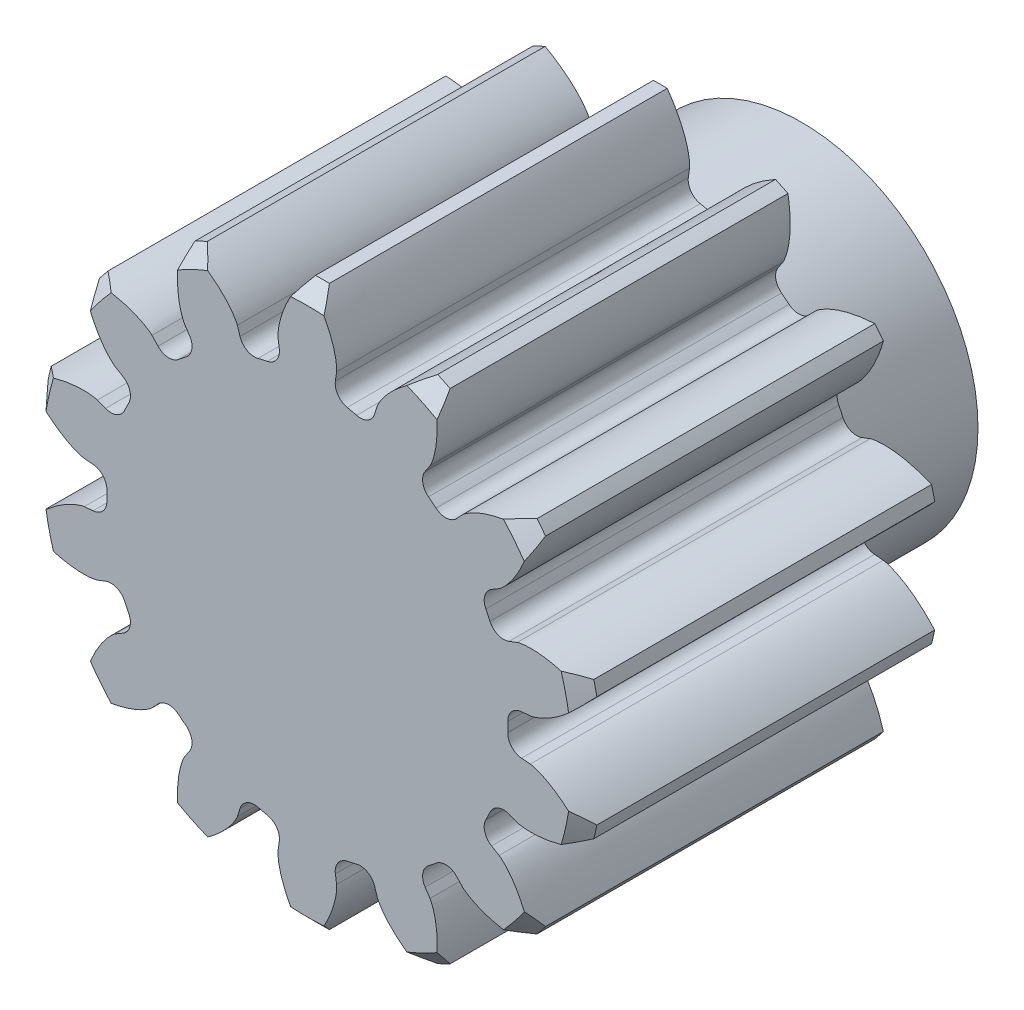
from build123d import *
from build123d.topology import SkipClean

# Parameters (mm, degrees)
SKETCH1_R                = 8
BOSS_EXTRUDE1_DEPTH      = 10
CUT_EXTRUDE1_DEPTH       = 16.099668871
FILLET1_R                = 0.355654565
FILLET2_R                = 0.355654565
CIRPATTERN1_COUNT        = 14
FILLET1_OF_CIRPATTERN1_R = 0.355654565
FILLET2_OF_CIRPATTERN1_R = 0.355654565
SKETCH4_R                = 2
BORE_DEPTH               = 16.019584955
SKETCH5_R                = 16
TOLERANCE_DEPTH          = 16.019584955
SKETCH7_R                = 5
SKETCH7_R_2              = 2
BOSS_EXTRUDE2_DEPTH      = 4
SKETCH8_R                = 2
BOSS_EXTRUDE3_DEPTH      = 4.2


with BuildPart() as part:
    # Sketch1 → Boss-Extrude1 (new body)
    with BuildSketch(Plane.XY):
        Circle(SKETCH1_R)
    extrude(amount=BOSS_EXTRUDE1_DEPTH)

    # Sketch2 → Cut-Extrude1 (cut, through all)
    with BuildSketch(Plane.XY.offset(10)):
        with BuildLine():
            Line((5.730573503, 0.472257693), (6.322720648, 0.521056656))
            add(Edge.make_bspline(
                [(6.322720648, 0.521056656), (6.325475459, 0.521328821), (6.333187667, 0.52223076), (6.347707195, 0.52448275), (6.371287999, 0.52893086), (6.414835682, 0.538848261), (6.466578901, 0.553467251), (6.52440654, 0.572634304), (6.585867562, 0.595867869), (6.637954923, 0.617357051), (6.68945384, 0.640294185), (6.740319148, 0.664489833), (6.801385563, 0.695375748), (6.873827242, 0.734595986), (6.957273971, 0.783580487), (7.050401835, 0.842814847), (7.143579001, 0.907050749), (7.233800283, 0.973416262), (7.323161939, 1.044027003), (7.408343747, 1.114864038), (7.494851143, 1.191992044), (7.573708707, 1.265000125), (7.65975709, 1.350629543), (7.728537068, 1.420862176), (7.797590498, 1.496542262), (7.83090097, 1.533834574), (7.847797593, 1.553084977)],
                knots=[0, 0, 0, 0, 0, 0.005376749, 0.015083688, 0.02853182, 0.046610139, 0.092110525, 0.119476176, 0.146842496, 0.174208854, 0.201574956, 0.228941013, 0.256307345, 0.307035032, 0.361767352, 0.416499661, 0.471231937, 0.525964282, 0.580696615, 0.635428982, 0.690161387, 0.744893688, 0.799626082, 0.854358408, 0.909090915, 0.909090915, 0.909090915, 0.909090915, 0.909090915], degree=4))
            ThreePointArc((7.847797593, 1.553084977), (8, 0), (7.847797593, -1.553084977))
            add(Edge.make_bspline(
                [(6.322720648, -0.521056656), (6.325475459, -0.521328821), (6.333187667, -0.52223076), (6.347707195, -0.52448275), (6.371287999, -0.52893086), (6.414835682, -0.538848261), (6.466578901, -0.553467251), (6.52440654, -0.572634304), (6.585867562, -0.595867869), (6.637954923, -0.617357051), (6.68945384, -0.640294185), (6.740319148, -0.664489833), (6.801385563, -0.695375748), (6.873827242, -0.734595986), (6.957273971, -0.783580487), (7.050401835, -0.842814847), (7.143579001, -0.907050749), (7.233800283, -0.973416262), (7.323161939, -1.044027003), (7.408343747, -1.114864038), (7.494851143, -1.191992044), (7.573708707, -1.265000125), (7.65975709, -1.350629543), (7.728537068, -1.420862176), (7.797590498, -1.496542262), (7.83090097, -1.533834574), (7.847797593, -1.553084977)],
                knots=[0, 0, 0, 0, 0, 0.005376749, 0.015083688, 0.02853182, 0.046610139, 0.092110525, 0.119476176, 0.146842496, 0.174208854, 0.201574956, 0.228941013, 0.256307345, 0.307035032, 0.361767352, 0.416499661, 0.471231937, 0.525964282, 0.580696615, 0.635428982, 0.690161387, 0.744893688, 0.799626082, 0.854358408, 0.909090915, 0.909090915, 0.909090915, 0.909090915, 0.909090915], degree=4))
            Line((6.322720648, -0.521056656), (5.730573503, -0.472257693))
            ThreePointArc((5.730573503, -0.472257693), (5.75, 0), (5.730573503, 0.472257693))
        make_face()
    cut_extrude1 = extrude(amount=-CUT_EXTRUDE1_DEPTH, mode=Mode.SUBTRACT)

    # Fillet1
    fillet1_edges = [part.edges().sort_by_distance(p)[0] for p in [
        (5.730573503, 0.472257693, 5),
    ]]
    fillet(fillet1_edges, radius=FILLET1_R)

    # Fillet2
    fillet2_edges = [part.edges().sort_by_distance(p)[0] for p in [
        (5.730573503, -0.472257693, 5),
    ]]
    fillet(fillet2_edges, radius=FILLET2_R)

    # CirPattern1: Cut-Extrude1 ×14 about axis
    cirpattern1_axis = Axis((0, 0, 10), (0, 0, -1))
    for i in range(1, CIRPATTERN1_COUNT):
        add(cut_extrude1.rotate(cirpattern1_axis, i * 360 / CIRPATTERN1_COUNT), mode=Mode.SUBTRACT)

    # Fillet1 of CirPattern1
    fillet1_of_cirpattern1_edges = [part.edges().sort_by_distance(p)[0] for p in [
        (5.367973255, -2.06091318, 5),
        (3.94218007, -4.185894922, 5),
        (1.735589774, -5.481808838, 5),
        (-0.814755362, -5.691983284, 5),
        (-3.203728206, -4.774790632, 5),
        (-4.958163388, -2.911892137, 5),
        (-5.730573503, -0.472257693, 5),
        (-5.367973255, 2.06091318, 5),
        (-3.94218007, 4.185894922, 5),
        (-1.735589774, 5.481808838, 5),
        (0.814755362, 5.691983284, 5),
        (3.203728206, 4.774790632, 5),
        (4.958163388, 2.911892137, 5),
    ]]
    fillet(fillet1_of_cirpattern1_edges, radius=FILLET1_OF_CIRPATTERN1_R)

    # Fillet2 of CirPattern1
    fillet2_of_cirpattern1_edges = [part.edges().sort_by_distance(p)[0] for p in [
        (4.958163388, -2.911892137, 5),
        (3.203728206, -4.774790632, 5),
        (0.814755362, -5.691983284, 5),
        (-1.735589774, -5.481808838, 5),
        (-3.94218007, -4.185894922, 5),
        (-5.367973255, -2.06091318, 5),
        (-5.730573503, 0.472257693, 5),
        (-4.958163388, 2.911892137, 5),
        (-3.203728206, 4.774790632, 5),
        (-0.814755362, 5.691983284, 5),
        (1.735589774, 5.481808838, 5),
        (3.94218007, 4.185894922, 5),
        (5.367973255, 2.06091318, 5),
    ]]
    fillet(fillet2_of_cirpattern1_edges, radius=FILLET2_OF_CIRPATTERN1_R)

    # Sketch4 → Bore (cut, through all)
    with BuildSketch(Plane.XY.offset(10)):
        Circle(SKETCH4_R)
    extrude(amount=-BORE_DEPTH, mode=Mode.SUBTRACT)

    # Sketch5 → TOLERANCE (cut, through all)
    with BuildSketch(Plane.XY.offset(10)):
        Circle(SKETCH5_R)
        with BuildLine():
            Line((6.316346609, -0.590768668), (6.068945037, -0.570380256))
            ThreePointArc((6.068945037, -0.570380256), (5.787375971, -0.430753494), (5.67837222, -0.135973993))
            ThreePointArc((5.67837222, -0.135973993), (5.68, 0), (5.67837222, 0.135973993))
            ThreePointArc((5.67837222, 0.135973993), (5.787375971, 0.430753494), (6.068945037, 0.570380256))
            Line((6.068945037, 0.570380256), (6.316346609, 0.590768668))
            add(Edge.make_bspline(
                [(6.316346609, 0.590768668), (6.354130738, 0.59464145), (6.390065274, 0.604717133), (6.461766907, 0.625430036), (6.497132103, 0.637415095), (6.602189372, 0.676852433), (6.670525006, 0.707679936), (6.869027417, 0.808304435), (6.994197707, 0.886761429), (7.354770586, 1.145846707), (7.573794334, 1.35105484), (7.772333196, 1.573447389)],
                knots=[0, 0, 0, 0, 0.0625, 0.0625, 0.125, 0.125, 0.25, 0.25, 0.5, 0.5, 1, 1, 1, 1], degree=3))
            ThreePointArc((7.772333196, 1.573447389), (7.731178344, 1.764591006), (7.685323477, 1.954661877))
            add(Edge.make_bspline(
                [(7.685323477, 1.954661877), (7.41025652, 2.068762215), (7.125421755, 2.158361645), (6.686362495, 2.235743079), (6.537881791, 2.252249383), (6.315009659, 2.2566167), (6.203811241, 2.253714765), (6.093111129, 2.240149255), (6.019470965, 2.22768354), (5.9824995, 2.221063392), (5.947156572, 2.208295906)],
                knots=[0, 0, 0, 0, 0.5, 0.5, 0.75, 0.75, 0.875, 0.9375, 0.9375, 1, 1, 1, 1], degree=3))
            Line((5.947156572, 2.208295906), (5.715409258, 2.119321712))
            ThreePointArc((5.715409258, 2.119321712), (5.401142514, 2.122952839), (5.175033496, 2.341245036))
            ThreePointArc((5.175033496, 2.341245036), (5.11750317, 2.464459638), (5.057039686, 2.586261706))
            ThreePointArc((5.057039686, 2.586261706), (5.027348641, 2.899143814), (5.220451822, 3.147111419))
            Line((5.220451822, 3.147111419), (5.434506735, 3.272824263))
            add(Edge.make_bspline(
                [(5.434506735, 3.272824263), (5.466868721, 3.292707438), (5.494872946, 3.317376725), (5.550486892, 3.367148579), (5.57714971, 3.393291127), (5.654691819, 3.474405581), (5.702884547, 3.531829922), (5.838069705, 3.708616432), (5.916803026, 3.833613094), (6.129255075, 4.223487573), (6.237552181, 4.503404555), (6.319937005, 4.789916101)],
                knots=[0, 0, 0, 0, 0.0625, 0.0625, 0.125, 0.125, 0.25, 0.25, 0.5, 0.5, 1, 1, 1, 1], degree=3))
            ThreePointArc((6.319937005, 4.789916101), (6.199923656, 4.944274129), (6.076141189, 5.095626385))
            add(Edge.make_bspline(
                [(6.076141189, 5.095626385), (5.778808143, 5.079080157), (5.483305151, 5.036221282), (5.054151881, 4.915438871), (4.913213572, 4.865887174), (4.710517812, 4.773121397), (4.611590602, 4.722259658), (4.517739101, 4.662006578), (4.456800277, 4.618824087), (4.426362512, 4.596818222), (4.400059239, 4.569980393)],
                knots=[0, 0, 0, 0, 0.5, 0.5, 0.75, 0.75, 0.875, 0.9375, 0.9375, 1, 1, 1, 1], degree=3))
            Line((4.400059239, 4.569980393), (4.22986658, 4.389266023))
            ThreePointArc((4.22986658, 4.389266023), (3.94514654, 4.256182325), (3.646715919, 4.354751773))
            ThreePointArc((3.646715919, 4.354751773), (3.541422075, 4.44080282), (3.434098422, 4.524308569))
            ThreePointArc((3.434098422, 4.524308569), (3.271593255, 4.793323146), (3.337984098, 5.100518568))
            Line((3.337984098, 5.100518568), (3.476296152, 5.306656873))
            add(Edge.make_bspline(
                [(3.476296152, 5.306656873), (3.496826308, 5.338612335), (3.51135364, 5.372989172), (3.539864876, 5.44196205), (3.552544419, 5.477084235), (3.587213202, 5.583810093), (3.605717861, 5.656457678), (3.650810688, 5.874391461), (3.66751294, 6.02117067), (3.689765425, 6.464614927), (3.66588632, 6.763799767), (3.61579978, 7.057683186)],
                knots=[0, 0, 0, 0, 0.0625, 0.0625, 0.125, 0.125, 0.25, 0.25, 0.5, 0.5, 1, 1, 1, 1], degree=3))
            ThreePointArc((3.61579978, 7.057683186), (3.440698051, 7.144683122), (3.263504619, 7.227339593))
            add(Edge.make_bspline(
                [(3.263504619, 7.227339593), (3.00279594, 7.083423984), (2.755152713, 6.916595528), (2.420904501, 6.621571711), (2.315423149, 6.515776335), (2.173050141, 6.344250862), (2.105987886, 6.255503112), (2.047573438, 6.160496322), (2.011405635, 6.095149877), (1.993530143, 6.062116827), (1.981476211, 6.026524217)],
                knots=[0, 0, 0, 0, 0.5, 0.5, 0.75, 0.75, 0.875, 0.9375, 0.9375, 1, 1, 1, 1], degree=3))
            Line((1.981476211, 6.026524217), (1.90654695, 5.789862367))
            ThreePointArc((1.90654695, 5.789862367), (1.707765911, 5.546422703), (1.396121531, 5.505746513))
            ThreePointArc((1.396121531, 5.505746513), (1.263918905, 5.537590541), (1.130991848, 5.566260633))
            ThreePointArc((1.130991848, 5.566260633), (0.867858702, 5.738126043), (0.794387686, 6.043705462))
            Line((0.794387686, 6.043705462), (0.829562482, 6.289441008))
            add(Edge.make_bspline(
                [(0.829562482, 6.289441008), (0.834194559, 6.327139585), (0.832367681, 6.364415218), (0.828129208, 6.438928196), (0.824314136, 6.476073638), (0.809243016, 6.587272536), (0.794394532, 6.660754618), (0.740463841, 6.876671216), (0.691826938, 7.01616155), (0.519472482, 7.425346011), (0.368146714, 7.684541483), (0.195509064, 7.927589558)],
                knots=[0, 0, 0, 0, 0.0625, 0.0625, 0.125, 0.125, 0.25, 0.25, 0.5, 0.5, 1, 1, 1, 1], degree=3))
            ThreePointArc((0.195509064, 7.927589558), (0, 7.93), (-0.195509064, 7.927589558))
            add(Edge.make_bspline(
                [(-0.195509064, 7.927589558), (-0.367956825, 7.684808818), (-0.518691509, 7.427053204), (-0.691832705, 7.016221065), (-0.740965226, 6.875136081), (-0.79481676, 6.658823638), (-0.816731559, 6.549767455), (-0.828139257, 6.438824216), (-0.832372561, 6.364256483), (-0.834145319, 6.326738847), (-0.829562482, 6.289441008)],
                knots=[0, 0, 0, 0, 0.5, 0.5, 0.75, 0.75, 0.875, 0.9375, 0.9375, 1, 1, 1, 1], degree=3))
            Line((-0.829562482, 6.289441008), (-0.794387686, 6.043705462))
            ThreePointArc((-0.794387686, 6.043705462), (-0.867858702, 5.738126043), (-1.130991848, 5.566260633))
            ThreePointArc((-1.130991848, 5.566260633), (-1.263918905, 5.537590541), (-1.396121531, 5.505746513))
            ThreePointArc((-1.396121531, 5.505746513), (-1.707765911, 5.546422703), (-1.90654695, 5.789862367))
            Line((-1.90654695, 5.789862367), (-1.981476211, 6.026524217))
            add(Edge.make_bspline(
                [(-1.981476211, 6.026524217), (-1.993659654, 6.062499243), (-2.011478904, 6.095290776), (-2.047627607, 6.160585644), (-2.067181671, 6.192397234), (-2.129007675, 6.286044864), (-2.174268377, 6.345807417), (-2.316540952, 6.5169419), (-2.420883875, 6.621515587), (-2.753708358, 6.915396252), (-3.002508864, 7.083265513), (-3.263504619, 7.227339593)],
                knots=[0, 0, 0, 0, 0.0625, 0.0625, 0.125, 0.125, 0.25, 0.25, 0.5, 0.5, 1, 1, 1, 1], degree=3))
            ThreePointArc((-3.263504619, 7.227339593), (-3.440698051, 7.144683122), (-3.61579978, 7.057683186))
            add(Edge.make_bspline(
                [(-3.61579978, 7.057683186), (-3.665831229, 6.764123018), (-3.689802516, 6.466491906), (-3.667543959, 6.021221789), (-3.650596351, 5.872790809), (-3.605260455, 5.654534727), (-3.577687301, 5.546770027), (-3.539828815, 5.441864007), (-3.511289163, 5.372844039), (-3.496608071, 5.338272647), (-3.476296152, 5.306656873)],
                knots=[0, 0, 0, 0, 0.5, 0.5, 0.75, 0.75, 0.875, 0.9375, 0.9375, 1, 1, 1, 1], degree=3))
            Line((-3.476296152, 5.306656873), (-3.337984098, 5.100518568))
            ThreePointArc((-3.337984098, 5.100518568), (-3.271593255, 4.793323146), (-3.434098422, 4.524308569))
            ThreePointArc((-3.434098422, 4.524308569), (-3.541422075, 4.44080282), (-3.646715919, 4.354751773))
            ThreePointArc((-3.646715919, 4.354751773), (-3.94514654, 4.256182325), (-4.22986658, 4.389266023))
            Line((-4.22986658, 4.389266023), (-4.400059239, 4.569980393))
            add(Edge.make_bspline(
                [(-4.400059239, 4.569980393), (-4.426645121, 4.597106574), (-4.456927424, 4.618919241), (-4.517826661, 4.662063551), (-4.549246796, 4.682240612), (-4.645582284, 4.739788915), (-4.712290768, 4.773995232), (-4.914726398, 4.866452316), (-5.054108945, 4.915397255), (-5.481483485, 5.035767454), (-5.778480738, 5.079061938), (-6.076141189, 5.095626385)],
                knots=[0, 0, 0, 0, 0.0625, 0.0625, 0.125, 0.125, 0.25, 0.25, 0.5, 0.5, 1, 1, 1, 1], degree=3))
            ThreePointArc((-6.076141189, 5.095626385), (-6.199923656, 4.944274129), (-6.319937005, 4.789916101))
            add(Edge.make_bspline(
                [(-6.319937005, 4.789916101), (-6.237642799, 4.503719697), (-6.130102883, 4.225162579), (-5.916853153, 3.833645693), (-5.837182097, 3.707267292), (-5.701638101, 3.530295865), (-5.630038197, 3.445166768), (-5.550411864, 3.367075892), (-5.494751884, 3.31727394), (-5.466524712, 3.292496079), (-5.434506735, 3.272824263)],
                knots=[0, 0, 0, 0, 0.5, 0.5, 0.75, 0.75, 0.875, 0.9375, 0.9375, 1, 1, 1, 1], degree=3))
            Line((-5.434506735, 3.272824263), (-5.220451822, 3.147111419))
            ThreePointArc((-5.220451822, 3.147111419), (-5.027348641, 2.899143814), (-5.057039686, 2.586261706))
            ThreePointArc((-5.057039686, 2.586261706), (-5.11750317, 2.464459638), (-5.175033496, 2.341245036))
            ThreePointArc((-5.175033496, 2.341245036), (-5.401142514, 2.122952839), (-5.715409258, 2.119321712))
            Line((-5.715409258, 2.119321712), (-5.947156572, 2.208295906))
            add(Edge.make_bspline(
                [(-5.947156572, 2.208295906), (-5.982879233, 2.221200569), (-6.019626807, 2.227714104), (-6.093214738, 2.240162595), (-6.1302778, 2.244708814), (-6.242042348, 2.25475964), (-6.31698618, 2.256634741), (-6.539490006, 2.252102168), (-6.686305755, 2.235724213), (-7.123583582, 2.158743151), (-7.409953633, 2.068887855), (-7.685323477, 1.954661877)],
                knots=[0, 0, 0, 0, 0.0625, 0.0625, 0.125, 0.125, 0.25, 0.25, 0.5, 0.5, 1, 1, 1, 1], degree=3))
            ThreePointArc((-7.685323477, 1.954661877), (-7.731178344, 1.764591006), (-7.772333196, 1.573447389))
            add(Edge.make_bspline(
                [(-7.772333196, 1.573447389), (-7.574012713, 1.351299456), (-7.356261193, 1.146987986), (-6.994257014, 0.88676905), (-6.86764234, 0.807474021), (-6.668736395, 0.70683861), (-6.56729098, 0.661205978), (-6.461667771, 0.625397101), (-6.389911605, 0.604677053), (-6.353729091, 0.594600283), (-6.316346609, 0.590768668)],
                knots=[0, 0, 0, 0, 0.5, 0.5, 0.75, 0.75, 0.875, 0.9375, 0.9375, 1, 1, 1, 1], degree=3))
            Line((-6.316346609, 0.590768668), (-6.068945037, 0.570380256))
            ThreePointArc((-6.068945037, 0.570380256), (-5.787375971, 0.430753494), (-5.67837222, 0.135973993))
            ThreePointArc((-5.67837222, 0.135973993), (-5.68, 0), (-5.67837222, -0.135973993))
            ThreePointArc((-5.67837222, -0.135973993), (-5.787375971, -0.430753494), (-6.068945037, -0.570380256))
            Line((-6.068945037, -0.570380256), (-6.316346609, -0.590768668))
            add(Edge.make_bspline(
                [(-6.316346609, -0.590768668), (-6.354130738, -0.59464145), (-6.390065274, -0.604717133), (-6.461766907, -0.625430036), (-6.497132103, -0.637415095), (-6.602189372, -0.676852433), (-6.670525006, -0.707679936), (-6.869027417, -0.808304435), (-6.994197707, -0.886761429), (-7.354770586, -1.145846707), (-7.573794334, -1.35105484), (-7.772333196, -1.573447389)],
                knots=[0, 0, 0, 0, 0.0625, 0.0625, 0.125, 0.125, 0.25, 0.25, 0.5, 0.5, 1, 1, 1, 1], degree=3))
            ThreePointArc((-7.772333196, -1.573447389), (-7.731178344, -1.764591006), (-7.685323477, -1.954661877))
            add(Edge.make_bspline(
                [(-7.685323477, -1.954661877), (-7.41025652, -2.068762215), (-7.125421755, -2.158361645), (-6.686362495, -2.235743079), (-6.537881791, -2.252249383), (-6.315009659, -2.2566167), (-6.203811241, -2.253714765), (-6.093111129, -2.240149255), (-6.019470965, -2.22768354), (-5.9824995, -2.221063392), (-5.947156572, -2.208295906)],
                knots=[0, 0, 0, 0, 0.5, 0.5, 0.75, 0.75, 0.875, 0.9375, 0.9375, 1, 1, 1, 1], degree=3))
            Line((-5.947156572, -2.208295906), (-5.715409258, -2.119321712))
            ThreePointArc((-5.715409258, -2.119321712), (-5.401142514, -2.122952839), (-5.175033496, -2.341245036))
            ThreePointArc((-5.175033496, -2.341245036), (-5.11750317, -2.464459638), (-5.057039686, -2.586261706))
            ThreePointArc((-5.057039686, -2.586261706), (-5.027348641, -2.899143814), (-5.220451822, -3.147111419))
            Line((-5.220451822, -3.147111419), (-5.434506735, -3.272824263))
            add(Edge.make_bspline(
                [(-5.434506735, -3.272824263), (-5.466868721, -3.292707438), (-5.494872946, -3.317376725), (-5.550486892, -3.367148579), (-5.57714971, -3.393291127), (-5.654691819, -3.474405581), (-5.702884547, -3.531829922), (-5.838069705, -3.708616432), (-5.916803026, -3.833613094), (-6.129255075, -4.223487573), (-6.237552181, -4.503404555), (-6.319937005, -4.789916101)],
                knots=[0, 0, 0, 0, 0.0625, 0.0625, 0.125, 0.125, 0.25, 0.25, 0.5, 0.5, 1, 1, 1, 1], degree=3))
            ThreePointArc((-6.319937005, -4.789916101), (-6.199923656, -4.944274129), (-6.076141189, -5.095626385))
            add(Edge.make_bspline(
                [(-6.076141189, -5.095626385), (-5.778808143, -5.079080157), (-5.483305151, -5.036221282), (-5.054151881, -4.915438871), (-4.913213572, -4.865887174), (-4.710517812, -4.773121397), (-4.611590602, -4.722259658), (-4.517739101, -4.662006578), (-4.456800277, -4.618824087), (-4.426362512, -4.596818222), (-4.400059239, -4.569980393)],
                knots=[0, 0, 0, 0, 0.5, 0.5, 0.75, 0.75, 0.875, 0.9375, 0.9375, 1, 1, 1, 1], degree=3))
            Line((-4.400059239, -4.569980393), (-4.22986658, -4.389266023))
            ThreePointArc((-4.22986658, -4.389266023), (-3.94514654, -4.256182325), (-3.646715919, -4.354751773))
            ThreePointArc((-3.646715919, -4.354751773), (-3.541422075, -4.44080282), (-3.434098422, -4.524308569))
            ThreePointArc((-3.434098422, -4.524308569), (-3.271593255, -4.793323146), (-3.337984098, -5.100518568))
            Line((-3.337984098, -5.100518568), (-3.476296152, -5.306656873))
            add(Edge.make_bspline(
                [(-3.476296152, -5.306656873), (-3.496826308, -5.338612335), (-3.51135364, -5.372989172), (-3.539864876, -5.44196205), (-3.552544419, -5.477084235), (-3.587213202, -5.583810093), (-3.605717861, -5.656457678), (-3.650810688, -5.874391461), (-3.66751294, -6.02117067), (-3.689765425, -6.464614927), (-3.66588632, -6.763799767), (-3.61579978, -7.057683186)],
                knots=[0, 0, 0, 0, 0.0625, 0.0625, 0.125, 0.125, 0.25, 0.25, 0.5, 0.5, 1, 1, 1, 1], degree=3))
            ThreePointArc((-3.61579978, -7.057683186), (-3.440698051, -7.144683122), (-3.263504619, -7.227339593))
            add(Edge.make_bspline(
                [(-3.263504619, -7.227339593), (-3.00279594, -7.083423984), (-2.755152713, -6.916595528), (-2.420904501, -6.621571711), (-2.315423149, -6.515776335), (-2.173050141, -6.344250862), (-2.105987886, -6.255503112), (-2.047573438, -6.160496322), (-2.011405635, -6.095149877), (-1.993530143, -6.062116827), (-1.981476211, -6.026524217)],
                knots=[0, 0, 0, 0, 0.5, 0.5, 0.75, 0.75, 0.875, 0.9375, 0.9375, 1, 1, 1, 1], degree=3))
            Line((-1.981476211, -6.026524217), (-1.90654695, -5.789862367))
            ThreePointArc((-1.90654695, -5.789862367), (-1.707765911, -5.546422703), (-1.396121531, -5.505746513))
            ThreePointArc((-1.396121531, -5.505746513), (-1.263918905, -5.537590541), (-1.130991848, -5.566260633))
            ThreePointArc((-1.130991848, -5.566260633), (-0.867858702, -5.738126043), (-0.794387686, -6.043705462))
            Line((-0.794387686, -6.043705462), (-0.829562482, -6.289441008))
            add(Edge.make_bspline(
                [(-0.829562482, -6.289441008), (-0.834194559, -6.327139585), (-0.832367681, -6.364415218), (-0.828129208, -6.438928196), (-0.824314136, -6.476073638), (-0.809243016, -6.587272536), (-0.794394532, -6.660754618), (-0.740463841, -6.876671216), (-0.691826938, -7.01616155), (-0.519472482, -7.425346011), (-0.368146714, -7.684541483), (-0.195509064, -7.927589558)],
                knots=[0, 0, 0, 0, 0.0625, 0.0625, 0.125, 0.125, 0.25, 0.25, 0.5, 0.5, 1, 1, 1, 1], degree=3))
            ThreePointArc((-0.195509064, -7.927589558), (0, -7.93), (0.195509064, -7.927589558))
            add(Edge.make_bspline(
                [(0.195509064, -7.927589558), (0.367956825, -7.684808818), (0.518691509, -7.427053204), (0.691832705, -7.016221065), (0.740965226, -6.875136081), (0.79481676, -6.658823638), (0.816731559, -6.549767455), (0.828139257, -6.438824216), (0.832372561, -6.364256483), (0.834145319, -6.326738847), (0.829562482, -6.289441008)],
                knots=[0, 0, 0, 0, 0.5, 0.5, 0.75, 0.75, 0.875, 0.9375, 0.9375, 1, 1, 1, 1], degree=3))
            Line((0.829562482, -6.289441008), (0.794387686, -6.043705462))
            ThreePointArc((0.794387686, -6.043705462), (0.867858702, -5.738126043), (1.130991848, -5.566260633))
            ThreePointArc((1.130991848, -5.566260633), (1.263918905, -5.537590541), (1.396121531, -5.505746513))
            ThreePointArc((1.396121531, -5.505746513), (1.707765911, -5.546422703), (1.90654695, -5.789862367))
            Line((1.90654695, -5.789862367), (1.981476211, -6.026524217))
            add(Edge.make_bspline(
                [(1.981476211, -6.026524217), (1.993659654, -6.062499243), (2.011478904, -6.095290776), (2.047627607, -6.160585644), (2.067181671, -6.192397234), (2.129007675, -6.286044864), (2.174268377, -6.345807417), (2.316540952, -6.5169419), (2.420883875, -6.621515587), (2.753708358, -6.915396252), (3.002508864, -7.083265513), (3.263504619, -7.227339593)],
                knots=[0, 0, 0, 0, 0.0625, 0.0625, 0.125, 0.125, 0.25, 0.25, 0.5, 0.5, 1, 1, 1, 1], degree=3))
            ThreePointArc((3.263504619, -7.227339593), (3.440698051, -7.144683122), (3.61579978, -7.057683186))
            add(Edge.make_bspline(
                [(3.61579978, -7.057683186), (3.665831229, -6.764123018), (3.689802516, -6.466491906), (3.667543959, -6.021221789), (3.650596351, -5.872790809), (3.605260455, -5.654534727), (3.577687301, -5.546770027), (3.539828815, -5.441864007), (3.511289163, -5.372844039), (3.496608071, -5.338272647), (3.476296152, -5.306656873)],
                knots=[0, 0, 0, 0, 0.5, 0.5, 0.75, 0.75, 0.875, 0.9375, 0.9375, 1, 1, 1, 1], degree=3))
            Line((3.476296152, -5.306656873), (3.337984098, -5.100518568))
            ThreePointArc((3.337984098, -5.100518568), (3.271593255, -4.793323146), (3.434098422, -4.524308569))
            ThreePointArc((3.434098422, -4.524308569), (3.541422075, -4.44080282), (3.646715919, -4.354751773))
            ThreePointArc((3.646715919, -4.354751773), (3.94514654, -4.256182325), (4.22986658, -4.389266023))
            Line((4.22986658, -4.389266023), (4.400059239, -4.569980393))
            add(Edge.make_bspline(
                [(4.400059239, -4.569980393), (4.426645121, -4.597106574), (4.456927424, -4.618919241), (4.517826661, -4.662063551), (4.549246796, -4.682240612), (4.645582284, -4.739788915), (4.712290768, -4.773995232), (4.914726398, -4.866452316), (5.054108945, -4.915397255), (5.481483485, -5.035767454), (5.778480738, -5.079061938), (6.076141189, -5.095626385)],
                knots=[0, 0, 0, 0, 0.0625, 0.0625, 0.125, 0.125, 0.25, 0.25, 0.5, 0.5, 1, 1, 1, 1], degree=3))
            ThreePointArc((6.076141189, -5.095626385), (6.199923656, -4.944274129), (6.319937005, -4.789916101))
            add(Edge.make_bspline(
                [(6.319937005, -4.789916101), (6.237642799, -4.503719697), (6.130102883, -4.225162579), (5.916853153, -3.833645693), (5.837182097, -3.707267292), (5.701638101, -3.530295865), (5.630038197, -3.445166768), (5.550411864, -3.367075892), (5.494751884, -3.31727394), (5.466524712, -3.292496079), (5.434506735, -3.272824263)],
                knots=[0, 0, 0, 0, 0.5, 0.5, 0.75, 0.75, 0.875, 0.9375, 0.9375, 1, 1, 1, 1], degree=3))
            Line((5.434506735, -3.272824263), (5.220451822, -3.147111419))
            ThreePointArc((5.220451822, -3.147111419), (5.027348641, -2.899143814), (5.057039686, -2.586261706))
            ThreePointArc((5.057039686, -2.586261706), (5.11750317, -2.464459638), (5.175033496, -2.341245036))
            ThreePointArc((5.175033496, -2.341245036), (5.401142514, -2.122952839), (5.715409258, -2.119321712))
            Line((5.715409258, -2.119321712), (5.947156572, -2.208295906))
            add(Edge.make_bspline(
                [(5.947156572, -2.208295906), (5.982879233, -2.221200569), (6.019626807, -2.227714104), (6.093214738, -2.240162595), (6.1302778, -2.244708814), (6.242042348, -2.25475964), (6.31698618, -2.256634741), (6.539490006, -2.252102168), (6.686305755, -2.235724213), (7.123583582, -2.158743151), (7.409953633, -2.068887855), (7.685323477, -1.954661877)],
                knots=[0, 0, 0, 0, 0.0625, 0.0625, 0.125, 0.125, 0.25, 0.25, 0.5, 0.5, 1, 1, 1, 1], degree=3))
            ThreePointArc((7.685323477, -1.954661877), (7.731178344, -1.764591006), (7.772333196, -1.573447389))
            add(Edge.make_bspline(
                [(7.772333196, -1.573447389), (7.574012713, -1.351299456), (7.356261193, -1.146987986), (6.994257014, -0.88676905), (6.86764234, -0.807474021), (6.668736395, -0.70683861), (6.56729098, -0.661205978), (6.461667771, -0.625397101), (6.389911605, -0.604677053), (6.353729091, -0.594600283), (6.316346609, -0.590768668)],
                knots=[0, 0, 0, 0, 0.5, 0.5, 0.75, 0.75, 0.875, 0.9375, 0.9375, 1, 1, 1, 1], degree=3))
        make_face(mode=Mode.SUBTRACT)
    extrude(amount=-TOLERANCE_DEPTH, mode=Mode.SUBTRACT)

    # Sketch6 → TopChamfer (revolve, cut)
    with BuildSketch(Plane(origin=(0, 0, 0), x_dir=(1, 0, 0), z_dir=(0, 1, 0))):
        Polygon((-8, -9.5), (-8, -10), (-7.5, -10), align=None)
    revolve(axis=Axis((0, 0, 7.90908368), (0, 0, -1)), mode=Mode.SUBTRACT)

    # Sketch7 → Boss-Extrude2 (add)
    with SkipClean():  # the faces are left unmerged after this step: merging them gives an invalid solid
        with BuildSketch(Plane(origin=(0, 0, 0), x_dir=(-1, 0, 0), z_dir=(0, 0, -1))):
            Circle(SKETCH7_R)
            Circle(SKETCH7_R_2, mode=Mode.SUBTRACT)
        extrude(amount=BOSS_EXTRUDE2_DEPTH)

    # Sketch8 → Boss-Extrude3 (add)
    with SkipClean():  # the faces are left unmerged after this step: merging them gives an invalid solid
        with BuildSketch(Plane.XY.offset(10)):
            Circle(SKETCH8_R)
        extrude(amount=-BOSS_EXTRUDE3_DEPTH)


solid = part.part
